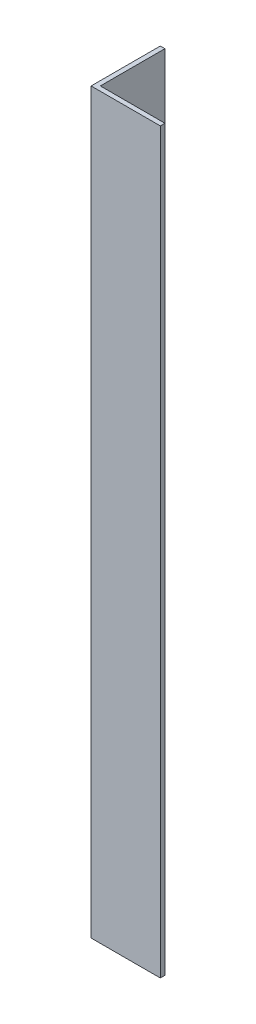
from build123d import *

# Parameters (mm, degrees)
EXTRUDE_1_DEPTH = 160


with BuildPart() as part:
    # Эскиз1 → Бобышка-Вытянуть1 (new body)
    with BuildSketch(Plane(origin=(0, 0, 0), x_dir=(1, 0, 0), z_dir=(0, 1, 0))):
        Polygon((0, 0), (0, 15), (1, 15), (1, 1), (15, 1), (15, 0), align=None)
    extrude(amount=EXTRUDE_1_DEPTH)


solid = part.part
